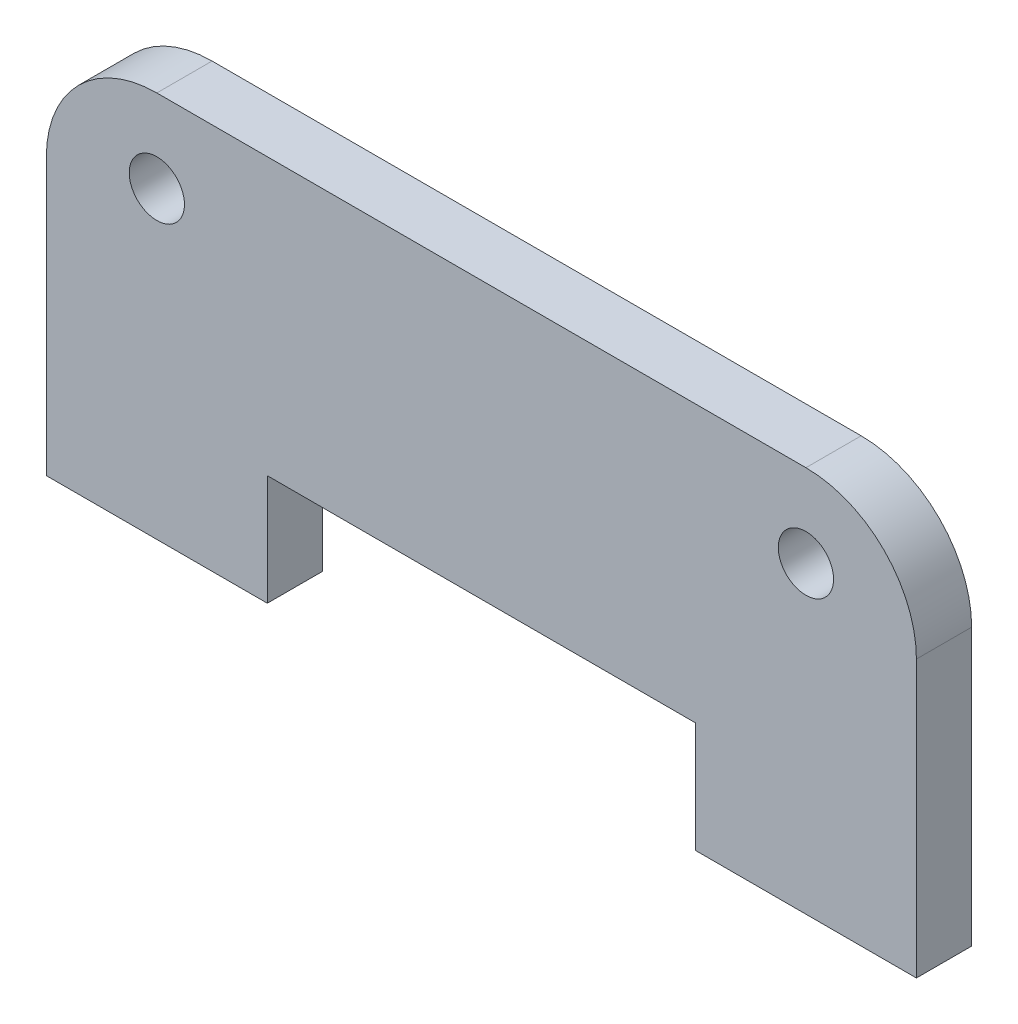
from build123d import *

# Parameters (mm, degrees)
SKETCH1_R           = 1
BOSS_EXTRUDE1_DEPTH = 2


with BuildPart() as part:
    # Sketch1 → Boss-Extrude1 (new body)
    with BuildSketch(Plane.XY):
        with BuildLine():
            Line((-15.75, -7), (-15.75, -11))
            Line((-15.75, -11), (-7.75, -11))
            Line((-7.75, -11), (-7.75, -7))
            Line((-7.75, -7), (7.75, -7))
            Line((7.75, -7), (7.75, -11))
            Line((7.75, -11), (15.75, -11))
            Line((15.75, -11), (15.75, -7))
            Line((15.75, -7), (15.75, -1))
            ThreePointArc((15.75, -1), (14.578427125, 1.828427125), (11.75, 3))
            Line((11.75, 3), (-11.75, 3))
            ThreePointArc((-11.75, 3), (-14.578427125, 1.828427125), (-15.75, -1))
            Line((-15.75, -1), (-15.75, -7))
        make_face()
        with Locations((-11.75, 0)):
            Circle(SKETCH1_R, mode=Mode.SUBTRACT)
        with Locations((11.75, 0)):
            Circle(SKETCH1_R, mode=Mode.SUBTRACT)
    extrude(amount=BOSS_EXTRUDE1_DEPTH)


solid = part.part
